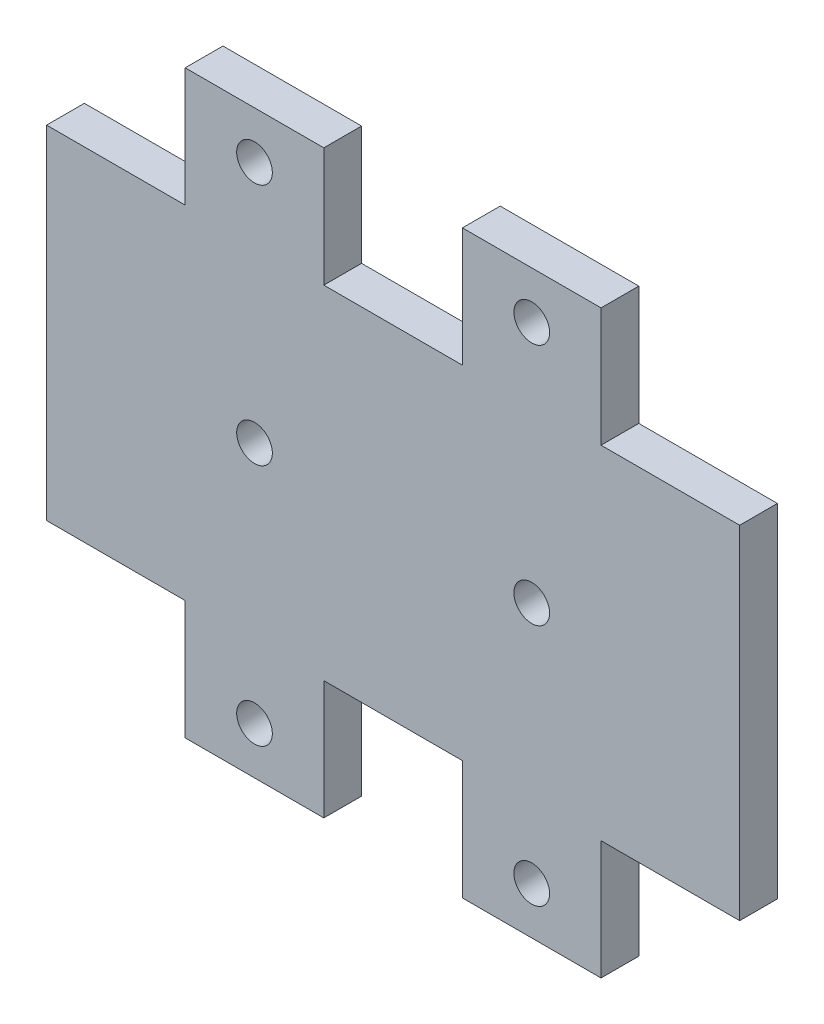
from build123d import *

# Parameters (mm, degrees)
SKETCH2_R           = 1.5
BOSS_EXTRUDE1_DEPTH = 3.175


with BuildPart() as part:
    # Sketch2 → Boss-Extrude1 (new body)
    with BuildSketch(Plane.XY):
        with BuildLine():
            Line((23.312, 14.4), (29.14, 14.4))
            Line((29.14, 14.4), (29.14, 0))
            Line((29.14, 0), (18.985, 0))
            ThreePointArc((18.985, 0), (17.485, 1.5), (15.985, 0))
            Line((15.985, 0), (0, 0))
            Line((0, 0), (0, 14.4))
            Line((0, 14.4), (11.656, 14.4))
            Line((11.656, 14.4), (11.656, 24.4))
            Line((11.656, 24.4), (23.312, 24.4))
            Line((23.312, 24.4), (23.312, 14.4))
        make_face()
        with Locations((17.484, 20.43125)):
            Circle(SKETCH2_R, mode=Mode.SUBTRACT)
    extrude(amount=BOSS_EXTRUDE1_DEPTH)

    # Mirror1: part across plane


with BuildPart() as part_1:
    add(part.part)
    add(part.part.mirror(Plane(origin=(0, 0, 3.175), x_dir=(0, 0, 1), z_dir=(0, 1, 0))))

    # Mirror2: part across plane


with BuildPart() as part_2:
    add(part_1.part)
    add(part_1.part.mirror(Plane(origin=(29.14, 14.4, 3.175), x_dir=(0, 0, 1), z_dir=(-1, 0, 0))))


solid = part_2.part
